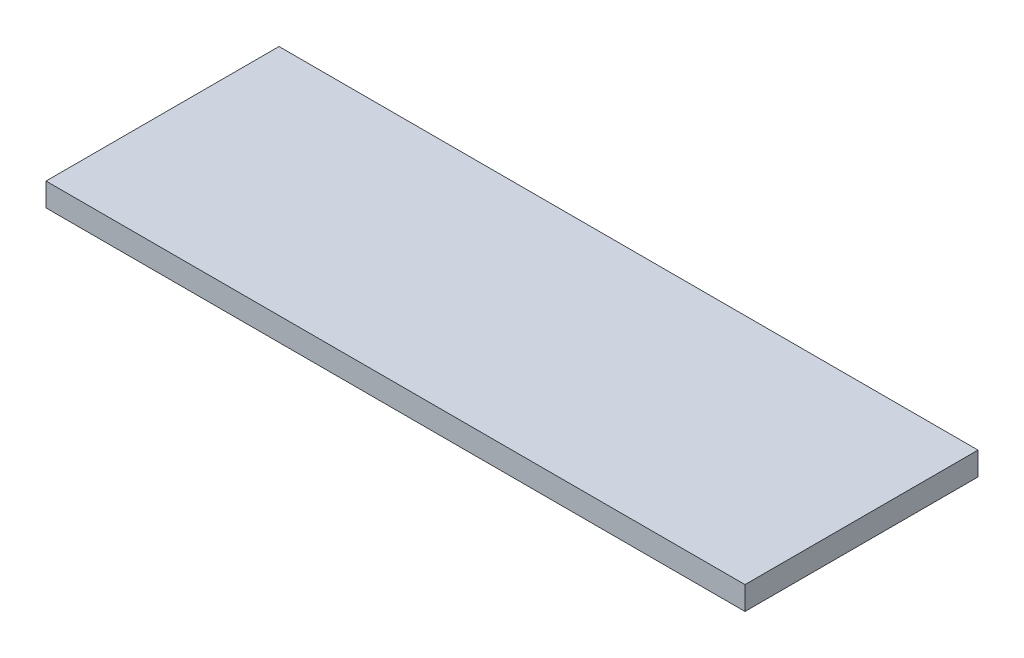
from build123d import *

# Parameters (mm, degrees)
SKETCH1_W           = 30
SKETCH1_H           = 10
BOSS_EXTRUDE1_DEPTH = 1


with BuildPart() as part:
    # Sketch1 → Boss-Extrude1 (new body)
    with BuildSketch(Plane(origin=(0, 0, 0), x_dir=(1, 0, 0), z_dir=(0, 1, 0))):
        with Locations((15, 5)):
            Rectangle(SKETCH1_W, SKETCH1_H)
    extrude(amount=BOSS_EXTRUDE1_DEPTH)


solid = part.part
